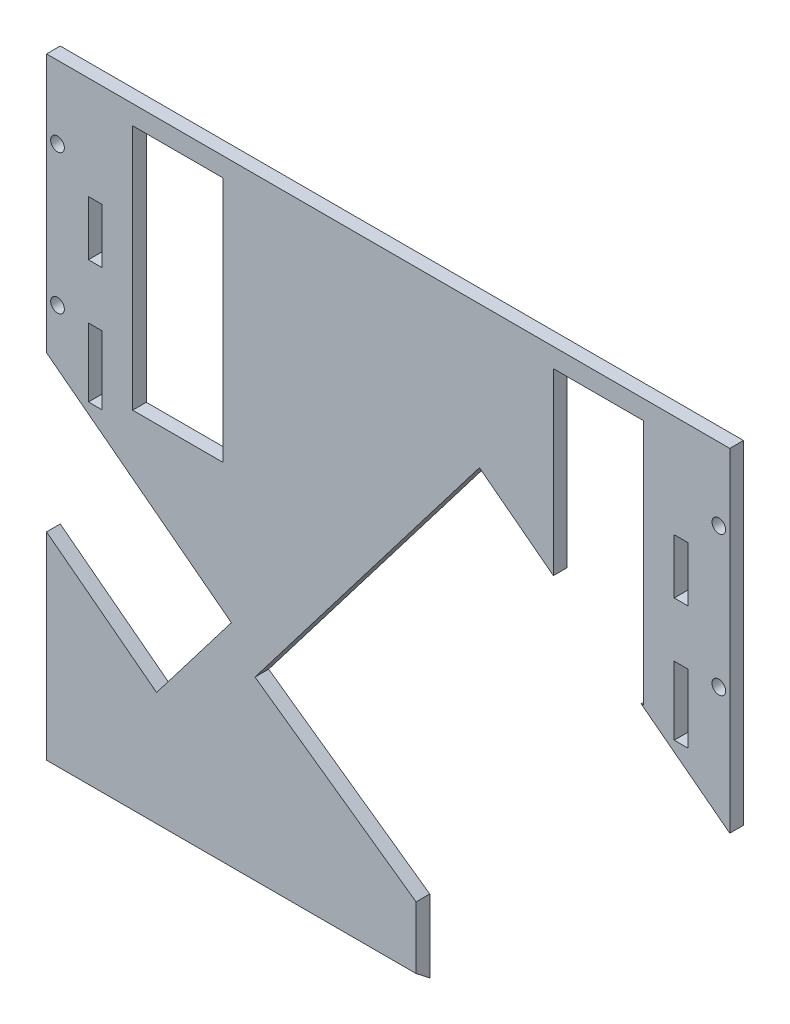
from build123d import *

# Parameters (mm, degrees)
SKETCH1_W           = 249.6
SKETCH1_H           = 284.42
SKETCH1_R           = 2.5
SKETCH1_W_2         = 33
SKETCH1_H_2         = 90
BOSS_EXTRUDE1_DEPTH = 5
SKETCH4_W           = 135
SKETCH4_H           = 244.46665057
CUT_EXTRUDE2_DEPTH  = 49.034766894
CUT_EXTRUDE3_DEPTH  = 6
CUT_EXTRUDE4_DEPTH  = 6
SKETCH7_W           = 5
SKETCH7_H           = 20
SKETCH7_H_2         = 25
CUT_EXTRUDE5_DEPTH  = 6


with BuildPart() as part:
    # Sketch1 → Boss-Extrude1 (new body)
    with BuildSketch(Plane.XY):
        with Locations((124.8, -142.21)):
            Rectangle(SKETCH1_W, SKETCH1_H)
        with Locations((245.6, -26.5)):
            Circle(SKETCH1_R, mode=Mode.SUBTRACT)
        with Locations((245.6, -77.5)):
            Circle(SKETCH1_R, mode=Mode.SUBTRACT)
        with Locations((4, -77.5)):
            Circle(SKETCH1_R, mode=Mode.SUBTRACT)
        with Locations((4, -26.5)):
            Circle(SKETCH1_R, mode=Mode.SUBTRACT)
        with Locations((201.66, -52)):
            Rectangle(SKETCH1_W_2, SKETCH1_H_2, mode=Mode.SUBTRACT)
        with Locations((47.94, -52)):
            Rectangle(SKETCH1_W_2, SKETCH1_H_2, mode=Mode.SUBTRACT)
    extrude(amount=BOSS_EXTRUDE1_DEPTH)

    # Sketch4 → Cut-Extrude2 (cut, through all)
    with BuildSketch(Plane(origin=(0, -141.18753923, 110.307795042), x_dir=(1, 0, 0), z_dir=(0, 0.788010754, -0.615661475))):
        with Locations((67.5, 84.166930672)):
            Rectangle(SKETCH4_W, SKETCH4_H)
    extrude(amount=-CUT_EXTRUDE2_DEPTH, mode=Mode.SUBTRACT)

    # Sketch5 → Cut-Extrude3 (cut, through all)
    with BuildSketch(Plane.XY.offset(5)):
        Polygon((76.149175745, -159.084342324), (158.149444505, -51.841832454), (328.08312673, -181.777318211), (207.31876811, -339.716714228), (135, -284.42), (135, -200.788988557), align=None)
    extrude(amount=-CUT_EXTRUDE3_DEPTH, mode=Mode.SUBTRACT)

    # Sketch6 → Cut-Extrude4 (cut, through all)
    with BuildSketch(Plane.XY.offset(5)):
        Polygon((0, -94.564658056), (67.52306177, -146.194456905), (40.18963885, -181.941960195), (-27.33342292, -130.312161346), align=None)
    extrude(amount=-CUT_EXTRUDE4_DEPTH, mode=Mode.SUBTRACT)

    # Sketch7 → Cut-Extrude5 (cut, through all)
    with BuildSketch(Plane.XY.offset(5)):
        with Locations((17.788155616, -47.477871486)):
            Rectangle(SKETCH7_W, SKETCH7_H)
        with Locations((231.811844384, -47.477871486)):
            Rectangle(SKETCH7_W, SKETCH7_H)
        with Locations((17.788155616, -89.977871486)):
            Rectangle(SKETCH7_W, SKETCH7_H_2)
        with Locations((231.811844384, -89.977871486)):
            Rectangle(SKETCH7_W, SKETCH7_H_2)
    extrude(amount=-CUT_EXTRUDE5_DEPTH, mode=Mode.SUBTRACT)


solid = part.part
